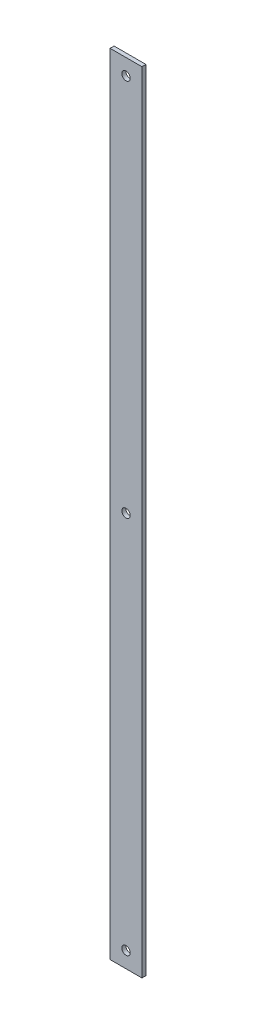
from build123d import *

# Parameters (mm, degrees)
SKETCH1_W           = 25.4
SKETCH1_H           = 628.65
BOSS_EXTRUDE1_DEPTH = 3.175
SKETCH2_R           = 3.3655
CUT_EXTRUDE1_DEPTH  = 4.175
LPATTERN1_COUNT     = 3
LPATTERN1_PITCH     = 301.625


with BuildPart() as part:
    # Sketch1 → Boss-Extrude1 (new body)
    with BuildSketch(Plane.XY):
        with Locations((-12.7, 314.325)):
            Rectangle(SKETCH1_W, SKETCH1_H)
    extrude(amount=BOSS_EXTRUDE1_DEPTH)

    # Sketch2 → Cut-Extrude1 (cut, through all)
    with BuildSketch(Plane.XY.offset(3.175)):
        with Locations((-12.7, 12.7)):
            Circle(SKETCH2_R)
    cut_extrude1 = extrude(amount=-CUT_EXTRUDE1_DEPTH, mode=Mode.SUBTRACT)

    # LPattern1: Cut-Extrude1 ×3
    with Locations(*[(0, i * LPATTERN1_PITCH, 0) for i in range(1, LPATTERN1_COUNT)]):
        add(cut_extrude1, mode=Mode.SUBTRACT)


solid = part.part
